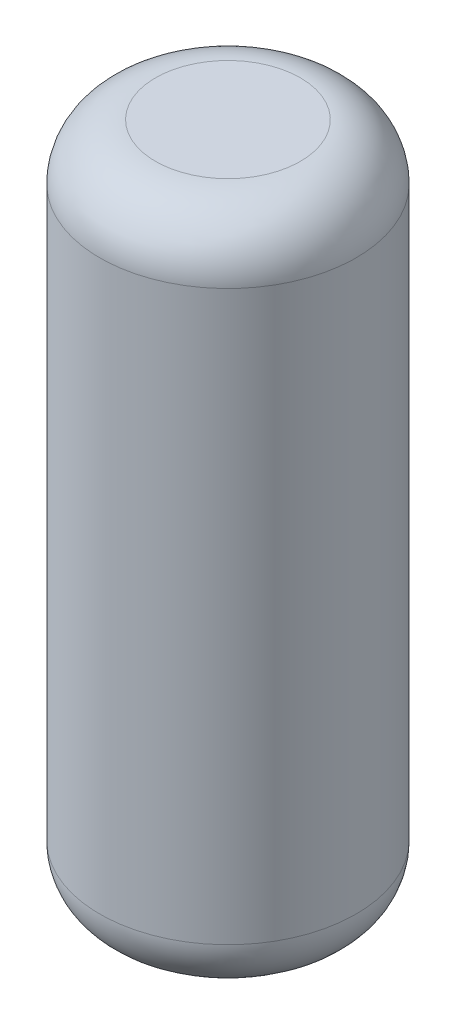
from build123d import *

# Parameters (mm, degrees)
SKETCH3_R           = 12.7
BOSS_EXTRUDE1_DEPTH = 19.05
SHELL1_T            = -2.54
BOSS_EXTRUDE2_START = 6.35
SKETCH6_R           = 12.7
BOSS_EXTRUDE2_DEPTH = 25.4
SKETCH7_R           = 7.9375
CUT_EXTRUDE3_DEPTH  = 25.4


with BuildPart() as part:
    # Sketch2 → Revolve1 (revolve)
    with BuildSketch(Plane.XY, mode=Mode.PRIVATE) as revolve1_sk:
        with BuildLine():
            Line((0, -232.41), (49.53, -232.41))
            ThreePointArc((49.53, -232.41), (76.470768363, -221.250768363), (87.63, -194.31))
            Line((87.63, -194.31), (87.63, -156.21))
            Line((87.63, -156.21), (87.63, 156.21))
            Line((87.63, 156.21), (87.63, 194.31))
            ThreePointArc((87.63, 194.31), (76.470768363, 221.250768363), (49.53, 232.41))
            Line((49.53, 232.41), (0, 232.41))
            Line((0, 232.41), (0, -232.41))
        make_face()
    revolve(revolve1_sk.sketch.rotate(Axis((0, -232.41, 0), (0, 1, 0)), 90), axis=Axis((0, -232.41, 0), (0, 1, 0)))

    # Sketch3 → Boss-Extrude1 (add)
    with BuildSketch(Plane(origin=(0, -232.41, 0), x_dir=(-1, 0, 0), z_dir=(0, -1, 0))):
        with Locations(Location((0, 0, 0), (0, 0, 270))):
            Circle(SKETCH3_R)
    extrude(amount=BOSS_EXTRUDE1_DEPTH)

    # Shell1
    shell1_openings = [part.faces().sort_by_distance(p)[0] for p in [
        (0, -251.46, 0),
    ]]
    offset(amount=SHELL1_T, openings=shell1_openings, kind=Kind.INTERSECTION)

    # Sketch6 → Boss-Extrude2 (add)
    with BuildSketch(Plane(origin=(0, -251.46, 0), x_dir=(-1, 0, 0), z_dir=(0, -1, 0)).offset(BOSS_EXTRUDE2_START)):
        with Locations(Location((0, 0, 0), (0, 0, 270))):
            Circle(SKETCH6_R)
    extrude(amount=-BOSS_EXTRUDE2_DEPTH)

    # Sketch7 → Cut-Extrude3 (cut)
    with BuildSketch(Plane.XZ.offset(257.81)):
        with Locations(Location((0, 0, 0), (0, 0, 270))):
            Circle(SKETCH7_R)
    extrude(amount=-CUT_EXTRUDE3_DEPTH, mode=Mode.SUBTRACT)


solid = part.part
